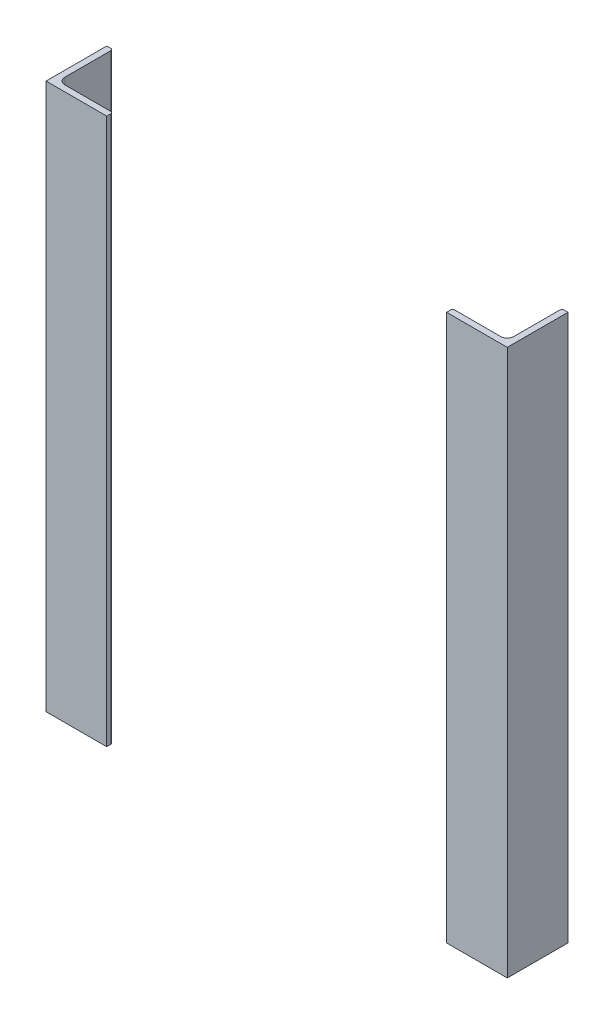
from build123d import *

# Parameters (mm, degrees)
L_ANGLE_EQUAL_L_ANGLE_5X5_1_DEPTH   = 450
L_ANGLE_EQUAL_L_ANGLE_5X5_1_2_DEPTH = 450


with BuildPart() as part:
    # Sketch1 → L angle (equal) L ANGLE 5X5(1) (new body)
    with BuildSketch(Plane(origin=(-190, 0, 0), x_dir=(1, 0, 0), z_dir=(0, -1, 0))):
        with BuildLine():
            Line((50, 0), (0, 0))
            Line((0, 0), (0, -50))
            Line((0, -50), (3.3333, -50))
            ThreePointArc((3.3333, -50), (4.511834872, -49.511834872), (5, -48.3333))
            Line((5, -48.3333), (5, -10.5))
            ThreePointArc((5, -10.5), (6.610912703, -6.610912703), (10.5, -5))
            Line((10.5, -5), (48.3333, -5))
            ThreePointArc((48.3333, -5), (49.511834872, -4.511834872), (50, -3.3333))
            Line((50, -3.3333), (50, 0))
        make_face()
    extrude(amount=L_ANGLE_EQUAL_L_ANGLE_5X5_1_DEPTH)


with BuildPart() as body_2:
    # Sketch1 on segment 2 (carried to segment 2) → L angle _equal_ L ANGLE 5X5_1 2 (new body)
    with BuildSketch(Plane(origin=(190, 0, 0), x_dir=(0, 0, -1), z_dir=(0, -1, 0))):
        with BuildLine():
            Line((50, 0), (0, 0))
            Line((0, 0), (0, -50))
            Line((0, -50), (3.3333, -50))
            ThreePointArc((3.3333, -50), (4.511834872, -49.511834872), (5, -48.3333))
            Line((5, -48.3333), (5, -10.5))
            ThreePointArc((5, -10.5), (6.610912703, -6.610912703), (10.5, -5))
            Line((10.5, -5), (48.3333, -5))
            ThreePointArc((48.3333, -5), (49.511834872, -4.511834872), (50, -3.3333))
            Line((50, -3.3333), (50, 0))
        make_face()
    extrude(amount=L_ANGLE_EQUAL_L_ANGLE_5X5_1_2_DEPTH)


solid = Compound([part.part, body_2.part])
